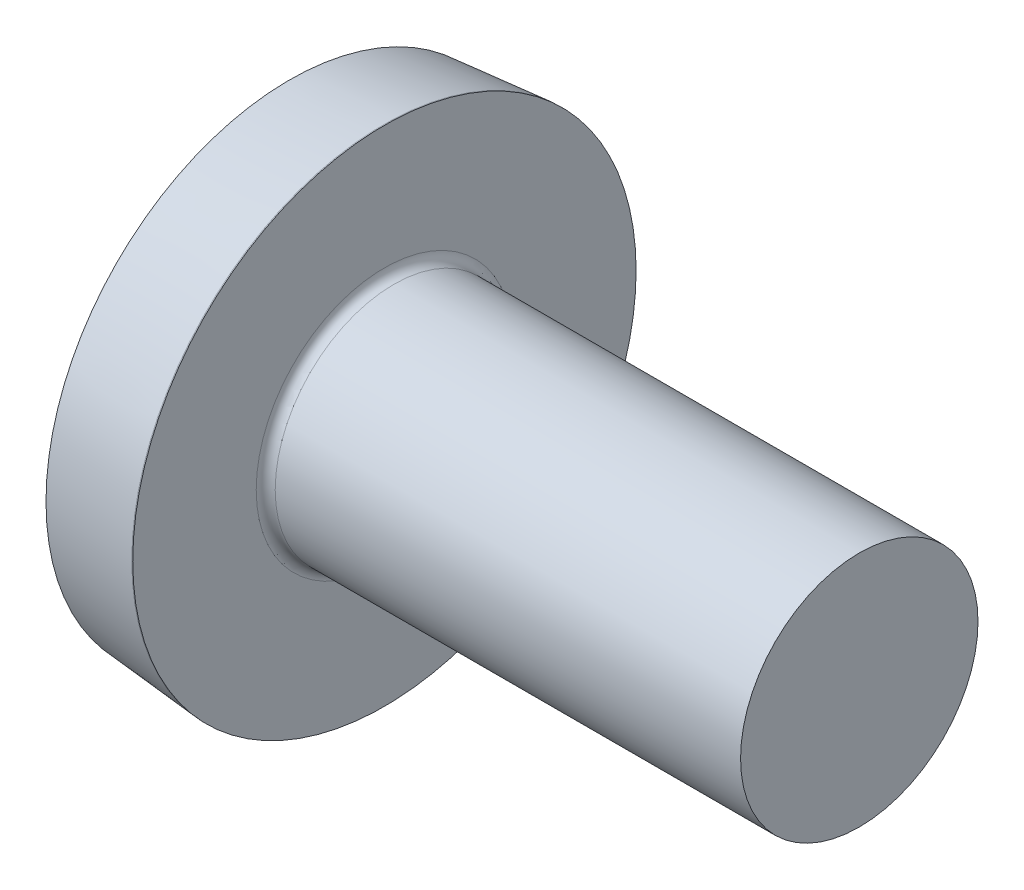
from build123d import *

# Parameters (mm, degrees)
FILLET1_R    = 0.1
SKETCH3_W    = 0.74
SKETCH3_H    = 2.5
SKETCH4_W    = 0.74
SKETCH4_H    = 1.183744774
RECPAT_COUNT = 2
RECPAT_ANGLE = 90


with BuildPart() as part:
    # BodySke → Base-Revolve (revolve)
    with BuildSketch(Plane.XY):
        with BuildLine():
            Line((1.5, 1.25), (1.5, 2.65))
            Line((1.5, 2.65), (1.49, 2.65))
            Line((1.49, 2.65), (0.5, 2.563386223))
            ThreePointArc((0.5, 2.563386223), (0.126166852, 1.305847323), (0, 0))
            Line((0, 0), (6.5, 0))
            Line((6.5, 0), (6.5, 1.25))
            Line((6.5, 1.25), (1.5, 1.25))
        make_face()
    revolve(axis=Axis((-25.4, 0, 0), (1, 0, 0)))

    # Fillet1
    fillet1_edges = [part.edges().sort_by_distance(p)[0] for p in [
        (1.5, -1.25, 0),
    ]]
    fillet(fillet1_edges, radius=FILLET1_R)

    # Sketch3 → Recess section 0
    with BuildSketch(Plane(origin=(0, 0, 0), x_dir=(0, 0, -1), z_dir=(1, 0, 0))):
        Rectangle(SKETCH3_W, SKETCH3_H)
    # Sketch4 → Recess section 1
    with BuildSketch(Plane(origin=(1.32, 0, 0), x_dir=(0, 0, -1), z_dir=(1, 0, 0))):
        Rectangle(SKETCH4_W, SKETCH4_H)
    recess = loft(mode=Mode.SUBTRACT)

    # RecPat: Recess ×2 about axis
    recpat_axis = Axis((0, 0, 0), (1, 0, 0))
    for i in range(1, RECPAT_COUNT):
        add(recess.rotate(recpat_axis, i * RECPAT_ANGLE / (RECPAT_COUNT - 1)), mode=Mode.SUBTRACT)

    # RecCorSke → RecessCore (revolve, cut)
    with BuildSketch(Plane.XY):
        Polygon((0, 0), (0, 0.648303392), (1.32, 0.556), (1.500655351, 0), align=None)
    revolve(axis=Axis((-3.175, 0, 0), (1, 0, 0)), mode=Mode.SUBTRACT)


solid = part.part
